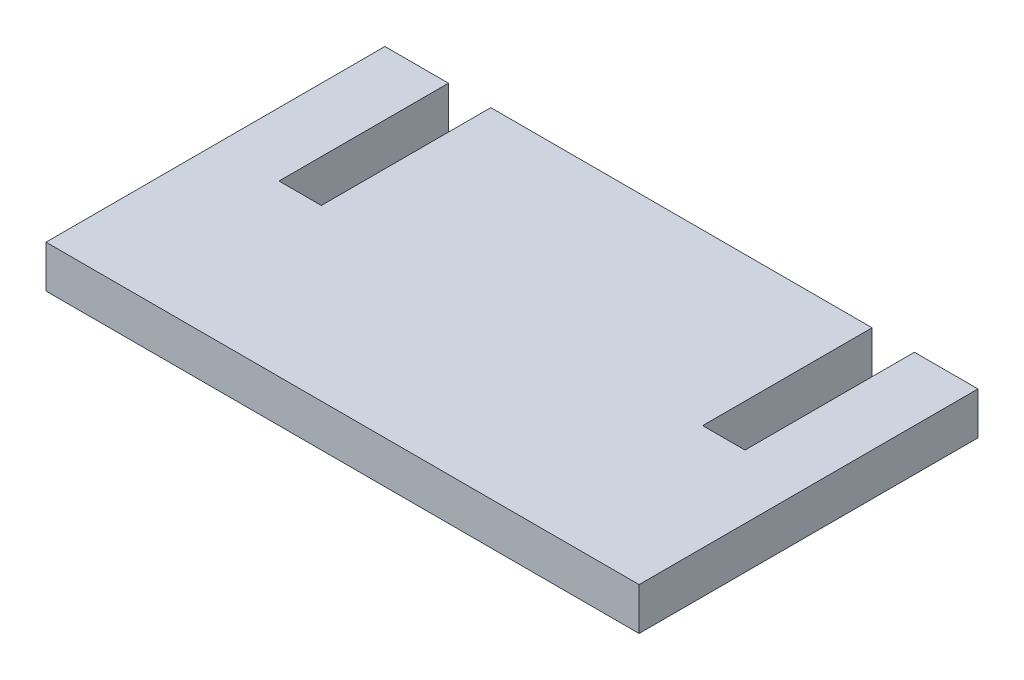
from build123d import *

# Parameters (mm, degrees)
SKETCH1_W           = 35.56
SKETCH1_H           = 20.32
BOSS_EXTRUDE1_DEPTH = 2.54
SKETCH2_W           = 2.54
SKETCH2_H           = 10.16
CUT_EXTRUDE1_DEPTH  = 3.54


with BuildPart() as part:
    # Sketch1 → Boss-Extrude1 (new body)
    with BuildSketch(Plane(origin=(0, 0, 0), x_dir=(1, 0, 0), z_dir=(0, 1, 0))):
        with Locations((17.78, -10.16)):
            Rectangle(SKETCH1_W, SKETCH1_H)
    extrude(amount=BOSS_EXTRUDE1_DEPTH)

    # Sketch2 → Cut-Extrude1 (cut, through all)
    with BuildSketch(Plane(origin=(0, 2.54, 0), x_dir=(1, 0, 0), z_dir=(0, 1, 0))):
        with Locations((5.08, -5.08)):
            Rectangle(SKETCH2_W, SKETCH2_H)
        with Locations((30.48, -5.08)):
            Rectangle(SKETCH2_W, SKETCH2_H)
    extrude(amount=-CUT_EXTRUDE1_DEPTH, mode=Mode.SUBTRACT)


solid = part.part
